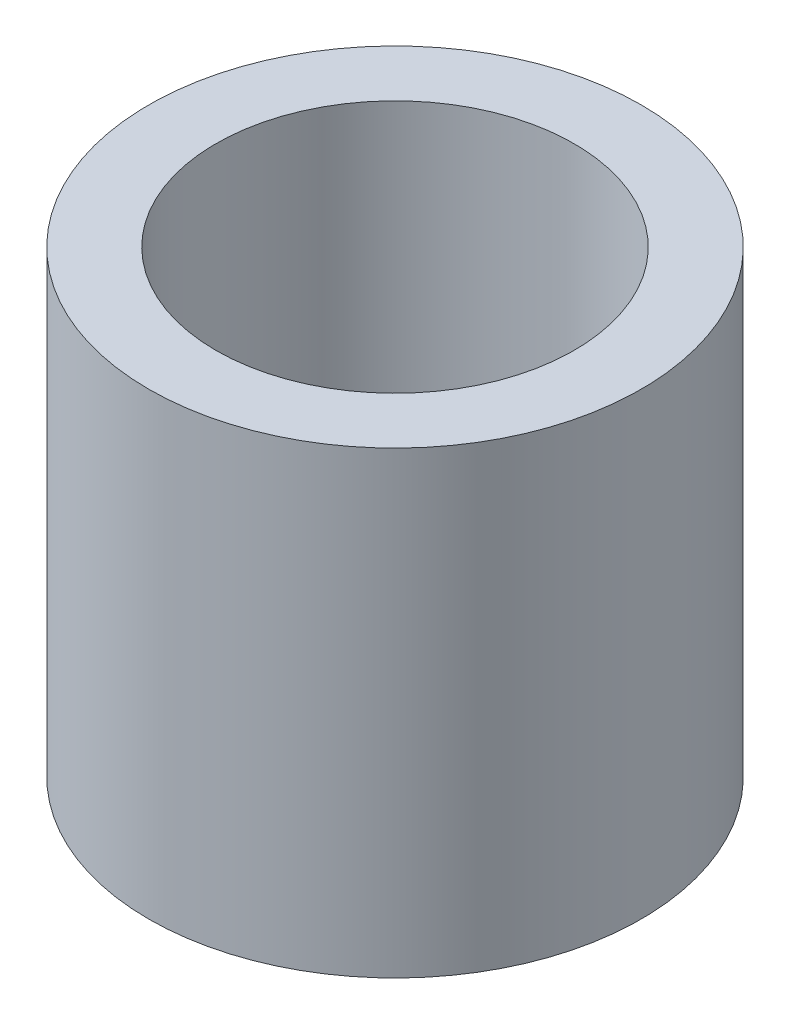
from build123d import *

# Parameters (mm, degrees)
SKETCH1_R           = 5.5
SKETCH1_R_2         = 4
BOSS_EXTRUDE1_DEPTH = 5.125


with BuildPart() as part:
    # Sketch1 → Boss-Extrude1 (new body, symmetric)
    with BuildSketch(Plane(origin=(0, 0, 0), x_dir=(1, 0, 0), z_dir=(0, 1, 0))):
        Circle(SKETCH1_R)
        Circle(SKETCH1_R_2, mode=Mode.SUBTRACT)
    extrude(amount=BOSS_EXTRUDE1_DEPTH, both=True)


solid = part.part
